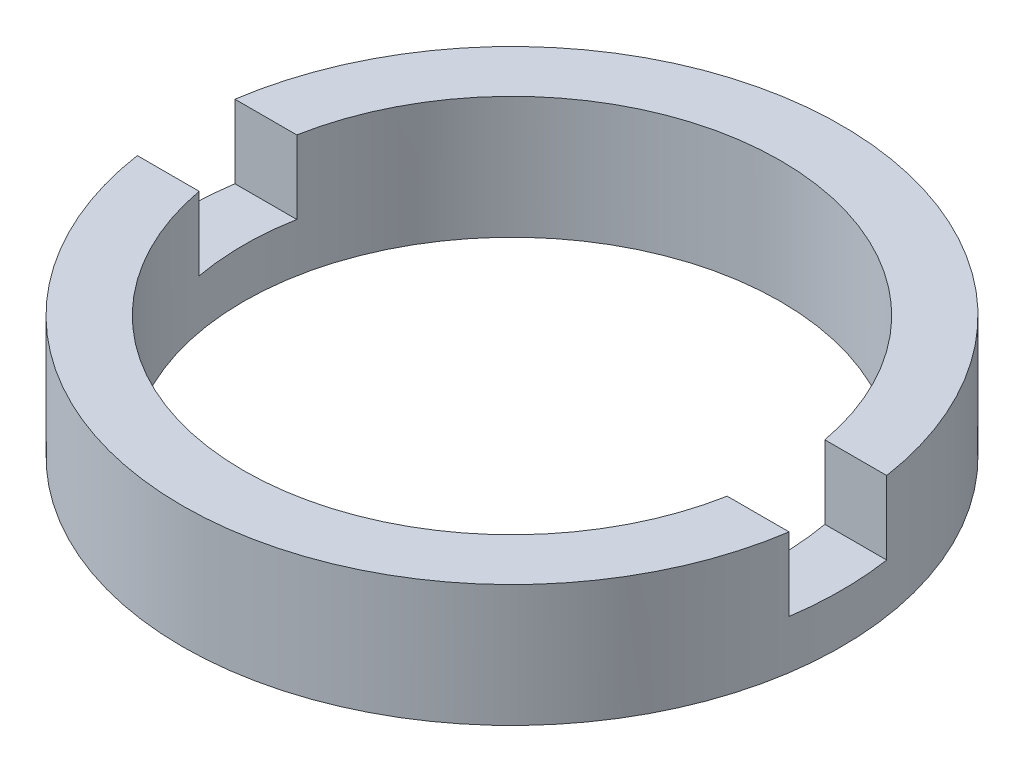
from build123d import *

# Parameters (mm, degrees)
SKETCH_1_W          = 1.25
SKETCH_1_H          = 2.5
SKETCH_2_W          = 53.705080546
SKETCH_2_H          = 2
CUT_EXTRUDE_1_DEPTH = 1.5


with BuildPart() as part:
    # 草图1 → 旋转1 (revolve)
    with BuildSketch(Plane.XY, mode=Mode.PRIVATE) as revolve_1_sk:
        with Locations((6.125, -3.214249787)):
            Rectangle(SKETCH_1_W, SKETCH_1_H)
    revolve(revolve_1_sk.sketch.rotate(Axis((0, 56.260842627, 0), (0, -1, 0)), 90), axis=Axis((0, 56.260842627, 0), (0, -1, 0)))  # turned: the seam where the file's is

    # 草图2 → 切除-拉伸1 (cut)
    with BuildSketch(Plane(origin=(0, -1.964249787, 0), x_dir=(1, 0, 0), z_dir=(0, 1, 0))):
        Rectangle(SKETCH_2_W, SKETCH_2_H)
    extrude(amount=-CUT_EXTRUDE_1_DEPTH, mode=Mode.SUBTRACT)


solid = part.part
